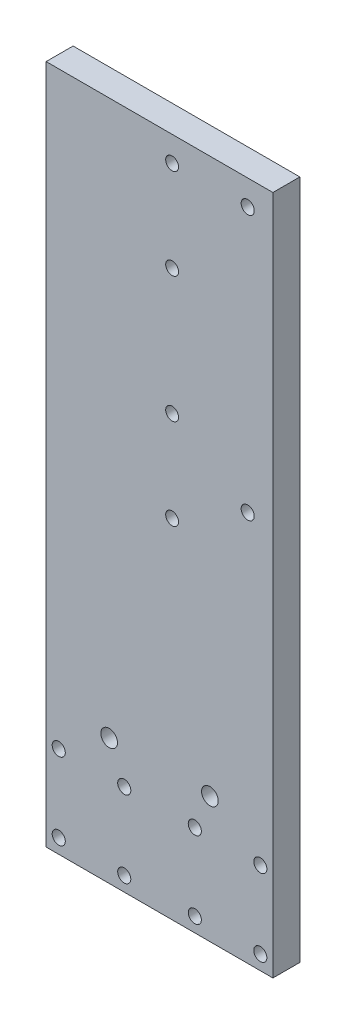
from build123d import *

# Parameters (mm, degrees)
ESBO_O1_W                               = 90
ESBO_O1_H                               = 270
RESSALTO_EXTRUS_O1_DEPTH                = 10.7
FURO_ROSCADO_PARA_CONDU_TE_DE_M5X0_81_D = 5.2
FURO_ROSCADO_PARA_CONDU_TE_DE_1_4_281_D = 6.6294
FURO_ROSCADO_PARA_CONDU_TE_DE_M5X0_82_D = 5.2
FURO_ROSCADO_PARA_CONDU_TE_DE_10_321_D  = 5.1054
ESBO_O16_R                              = 11
CORTE_EXTRUS_O1_DEPTH                   = 7


with BuildPart() as part:
    # Esboço1 → Ressalto-extrusão1 (new body)
    with BuildSketch(Plane.XY):
        Rectangle(ESBO_O1_W, ESBO_O1_H)
    extrude(amount=RESSALTO_EXTRUS_O1_DEPTH)

    # Furo roscado para conduíte de M5x0.81 (through all)
    with Locations(Plane(origin=(0, 0, 0), x_dir=(-1, 0, 0), z_dir=(0, 0, -1))):
        with Locations((-40, -98.75), (-40, -129.25), (-14, -129.25), (-14, -98.75), (14, -98.75), (14, -129.25), (40, -129.25), (40, -98.75)):
            Hole(FURO_ROSCADO_PARA_CONDU_TE_DE_M5X0_81_D / 2)

    # Furo roscado para conduíte de 1/4-281 (through all)
    with Locations(Plane(origin=(0, 0, 0), x_dir=(-1, 0, 0), z_dir=(0, 0, -1))):
        with Locations((-20, -85), (20, -85)):
            Hole(FURO_ROSCADO_PARA_CONDU_TE_DE_1_4_281_D / 2)

    # Furo roscado para conduíte de M5x0.82 (through all)
    with Locations(Plane(origin=(0, 0, 0), x_dir=(-1, 0, 0), z_dir=(0, 0, -1))):
        with Locations((-35, 125), (-35, 20)):
            Hole(FURO_ROSCADO_PARA_CONDU_TE_DE_M5X0_82_D / 2)

    # Furo roscado para conduíte de #10-321 (through all)
    with Locations(Plane(origin=(0, 0, 0), x_dir=(-1, 0, 0), z_dir=(0, 0, -1))):
        with Locations((-5, 125), (-5, 89), (-5, 39), (-5, 3)):
            Hole(FURO_ROSCADO_PARA_CONDU_TE_DE_10_321_D / 2)

    # Esboço16 → Corte-extrusão1 (cut)
    with BuildSketch(Plane(origin=(0, 0, 0), x_dir=(-1, 0, 0), z_dir=(0, 0, -1))):
        with Locations((-4, 64)):
            Circle(ESBO_O16_R)
    extrude(amount=-CORTE_EXTRUS_O1_DEPTH, mode=Mode.SUBTRACT)


solid = part.part
